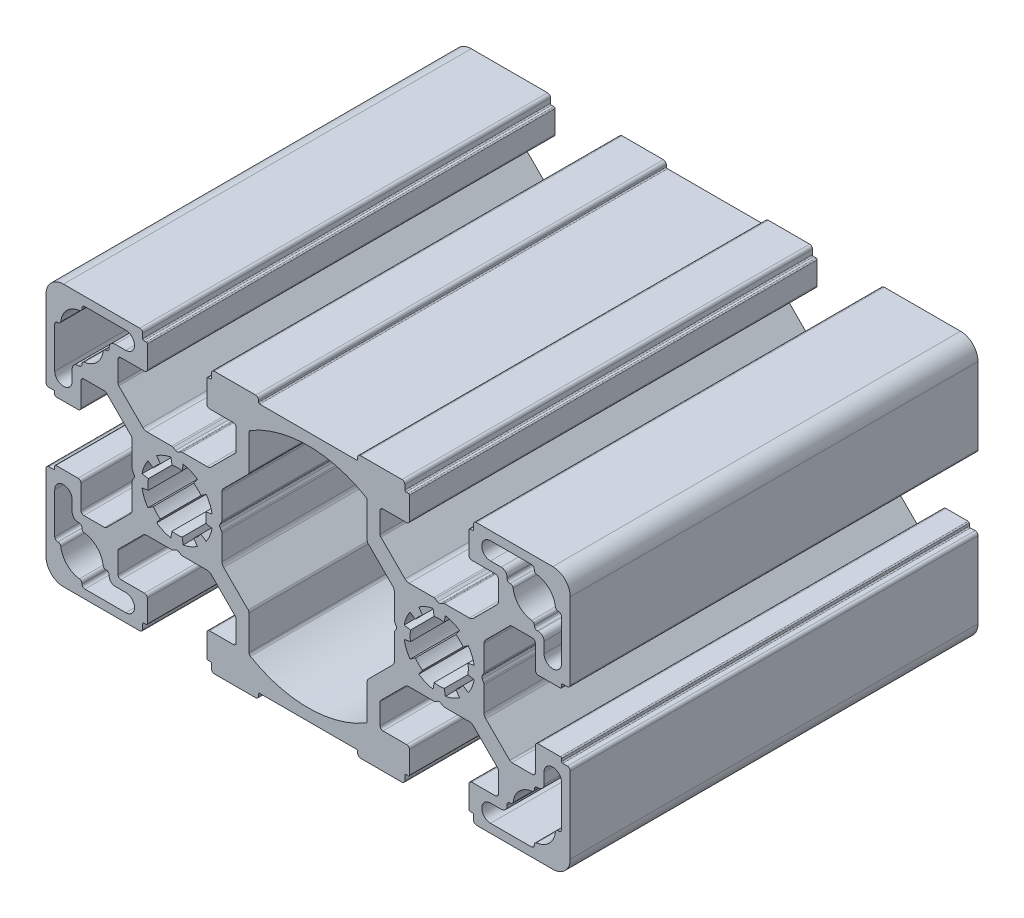
from build123d import *

# Parameters (mm, degrees)
EXTRUDE_2_DEPTH = 70


with BuildPart() as part:
    # Эскиз1 → Бобышка-Вытянуть2 (new body)
    with BuildSketch(Plane.XY):
        with BuildLine():
            Line((-35.141853673, 36.152210307), (-35.141853673, 40.388068593))
            ThreePointArc((-35.141853673, 40.388068593), (-35.21797414, 40.770752026), (-35.434746892, 41.095175374))
            Line((-35.434746892, 41.095175374), (-37.681504654, 43.341933137))
            Line((-37.681504654, 43.341933137), (-39.566246974, 45.226675456))
            ThreePointArc((-39.566246974, 45.226675456), (-39.728458648, 45.335061832), (-39.919800364, 45.373122066))
            Line((-39.919800364, 45.373122066), (-43.441373239, 45.373122066))
            ThreePointArc((-43.441373239, 45.373122066), (-43.79492663, 45.226675456), (-43.941373239, 44.873122066))
            Line((-43.941373239, 44.873122066), (-43.941373239, 40.823122066))
            ThreePointArc((-43.941373239, 40.823122066), (-44.087819849, 40.469568675), (-44.441373239, 40.323122066))
            Line((-44.441373239, 40.323122066), (-48.241373239, 40.323122066))
            ThreePointArc((-48.241373239, 40.323122066), (-48.382794596, 40.381700709), (-48.441373239, 40.523122066))
            Line((-48.441373239, 40.523122066), (-48.441373239, 40.923122066))
            ThreePointArc((-48.441373239, 40.923122066), (-48.499951883, 41.064543422), (-48.641373239, 41.123122066))
            Line((-48.641373239, 41.123122066), (-49.441373239, 41.123122066))
            ThreePointArc((-49.441373239, 41.123122066), (-49.79492663, 41.269568675), (-49.941373239, 41.623122066))
            Line((-49.941373239, 41.623122066), (-49.941373239, 54.723122066))
            ThreePointArc((-49.941373239, 54.723122066), (-49.062693583, 56.844442409), (-46.941373239, 57.723122066))
            Line((-46.941373239, 57.723122066), (-33.841373239, 57.723122066))
            ThreePointArc((-33.841373239, 57.723122066), (-33.487819849, 57.576675456), (-33.341373239, 57.223122066))
            Line((-33.341373239, 57.223122066), (-33.341373239, 56.423122066))
            ThreePointArc((-33.341373239, 56.423122066), (-33.282794596, 56.281700709), (-33.141373239, 56.223122066))
            Line((-33.141373239, 56.223122066), (-32.741373239, 56.223122066))
            ThreePointArc((-32.741373239, 56.223122066), (-32.599951883, 56.164543422), (-32.541373239, 56.023122066))
            Line((-32.541373239, 56.023122066), (-32.541373239, 52.223122066))
            ThreePointArc((-32.541373239, 52.223122066), (-32.687819849, 51.869568675), (-33.041373239, 51.723122066))
            Line((-33.041373239, 51.723122066), (-37.091373239, 51.723122066))
            ThreePointArc((-37.091373239, 51.723122066), (-37.44492663, 51.576675456), (-37.591373239, 51.223122066))
            Line((-37.591373239, 51.223122066), (-37.591373239, 47.70154919))
            ThreePointArc((-37.591373239, 47.70154919), (-37.553313006, 47.510207474), (-37.44492663, 47.3479958))
            Line((-37.44492663, 47.3479958), (-35.560184311, 45.463253481))
            Line((-35.560184311, 45.463253481), (-33.313426548, 43.216495718))
            ThreePointArc((-33.313426548, 43.216495718), (-32.989003199, 42.999722967), (-32.606319767, 42.923602499))
            Line((-32.606319767, 42.923602499), (-28.370461481, 42.923602499))
            ThreePointArc((-28.370461481, 42.923602499), (-28.241051958, 42.906565412), (-28.120461481, 42.856615201))
            Line((-28.120461481, 42.856615201), (-27.691373239, 42.608880989))
            ThreePointArc((-27.691373239, 42.608880989), (-27.441373239, 42.541893691), (-27.191373239, 42.608880989))
            Line((-27.191373239, 42.608880989), (-26.762284998, 42.856615201))
            ThreePointArc((-26.762284998, 42.856615201), (-26.64169452, 42.906565412), (-26.512284998, 42.923602499))
            Line((-26.512284998, 42.923602499), (-22.276426712, 42.923602499))
            ThreePointArc((-22.276426712, 42.923602499), (-21.89374328, 42.999722967), (-21.569319931, 43.216495718))
            Line((-21.569319931, 43.216495718), (-19.322562168, 45.463253481))
            Line((-19.322562168, 45.463253481), (-17.437819849, 47.3479958))
            ThreePointArc((-17.437819849, 47.3479958), (-17.329433473, 47.510207474), (-17.291373239, 47.70154919))
            Line((-17.291373239, 47.70154919), (-17.291373239, 51.223122066))
            ThreePointArc((-17.291373239, 51.223122066), (-17.437819849, 51.576675456), (-17.791373239, 51.723122066))
            Line((-17.791373239, 51.723122066), (-21.841373239, 51.723122066))
            ThreePointArc((-21.841373239, 51.723122066), (-22.19492663, 51.869568675), (-22.341373239, 52.223122066))
            Line((-22.341373239, 52.223122066), (-22.341373239, 56.023122066))
            ThreePointArc((-22.341373239, 56.023122066), (-22.282794596, 56.164543422), (-22.141373239, 56.223122066))
            Line((-22.141373239, 56.223122066), (-21.741373239, 56.223122066))
            ThreePointArc((-21.741373239, 56.223122066), (-21.599951883, 56.281700709), (-21.541373239, 56.423122066))
            Line((-21.541373239, 56.423122066), (-21.541373239, 57.223122066))
            ThreePointArc((-21.541373239, 57.223122066), (-21.39492663, 57.576675456), (-21.041373239, 57.723122066))
            Line((-21.041373239, 57.723122066), (-13.941373239, 57.723122066))
            ThreePointArc((-13.941373239, 57.723122066), (-13.587819849, 57.576675456), (-13.441373239, 57.223122066))
            Line((-13.441373239, 57.223122066), (-13.441373239, 56.923122066))
            ThreePointArc((-13.441373239, 56.923122066), (-13.382794596, 56.781700709), (-13.241373239, 56.723122066))
            Line((-13.241373239, 56.723122066), (3.358626761, 56.723122066))
            ThreePointArc((3.358626761, 56.723122066), (3.500048117, 56.781700709), (3.558626761, 56.923122066))
            Line((3.558626761, 56.923122066), (3.558626761, 57.223122066))
            ThreePointArc((3.558626761, 57.223122066), (3.70507337, 57.576675456), (4.058626761, 57.723122066))
            Line((4.058626761, 57.723122066), (11.158626761, 57.723122066))
            ThreePointArc((11.158626761, 57.723122066), (11.512180151, 57.576675456), (11.658626761, 57.223122066))
            Line((11.658626761, 57.223122066), (11.658626761, 56.423122066))
            ThreePointArc((11.658626761, 56.423122066), (11.717205404, 56.281700709), (11.858626761, 56.223122066))
            Line((11.858626761, 56.223122066), (12.258626761, 56.223122066))
            ThreePointArc((12.258626761, 56.223122066), (12.400048117, 56.164543422), (12.458626761, 56.023122066))
            Line((12.458626761, 56.023122066), (12.458626761, 52.223122066))
            ThreePointArc((12.458626761, 52.223122066), (12.312180151, 51.869568675), (11.958626761, 51.723122066))
            Line((11.958626761, 51.723122066), (7.908626761, 51.723122066))
            ThreePointArc((7.908626761, 51.723122066), (7.55507337, 51.576675456), (7.408626761, 51.223122066))
            Line((7.408626761, 51.223122066), (7.408626761, 47.70154919))
            ThreePointArc((7.408626761, 47.70154919), (7.446686994, 47.510207474), (7.55507337, 47.3479958))
            Line((7.55507337, 47.3479958), (9.439815689, 45.463253481))
            Line((9.439815689, 45.463253481), (11.686573452, 43.216495718))
            ThreePointArc((11.686573452, 43.216495718), (12.010996801, 42.999722967), (12.393680233, 42.923602499))
            Line((12.393680233, 42.923602499), (16.629538519, 42.923602499))
            ThreePointArc((16.629538519, 42.923602499), (16.758948042, 42.906565412), (16.879538519, 42.856615201))
            Line((16.879538519, 42.856615201), (17.308626761, 42.608880989))
            ThreePointArc((17.308626761, 42.608880989), (17.558626761, 42.541893691), (17.808626761, 42.608880989))
            Line((17.808626761, 42.608880989), (18.237715002, 42.856615201))
            ThreePointArc((18.237715002, 42.856615201), (18.35830548, 42.906565412), (18.487715002, 42.923602499))
            Line((18.487715002, 42.923602499), (22.723573288, 42.923602499))
            ThreePointArc((22.723573288, 42.923602499), (23.10625672, 42.999722967), (23.430680069, 43.216495718))
            Line((23.430680069, 43.216495718), (25.677437832, 45.463253481))
            Line((25.677437832, 45.463253481), (27.562180151, 47.3479958))
            ThreePointArc((27.562180151, 47.3479958), (27.670566527, 47.510207474), (27.708626761, 47.70154919))
            Line((27.708626761, 47.70154919), (27.708626761, 51.223122066))
            ThreePointArc((27.708626761, 51.223122066), (27.562180151, 51.576675456), (27.208626761, 51.723122066))
            Line((27.208626761, 51.723122066), (23.158626761, 51.723122066))
            ThreePointArc((23.158626761, 51.723122066), (22.80507337, 51.869568675), (22.658626761, 52.223122066))
            Line((22.658626761, 52.223122066), (22.658626761, 56.023122066))
            ThreePointArc((22.658626761, 56.023122066), (22.717205404, 56.164543422), (22.858626761, 56.223122066))
            Line((22.858626761, 56.223122066), (23.258626761, 56.223122066))
            ThreePointArc((23.258626761, 56.223122066), (23.400048117, 56.281700709), (23.458626761, 56.423122066))
            Line((23.458626761, 56.423122066), (23.458626761, 57.223122066))
            ThreePointArc((23.458626761, 57.223122066), (23.60507337, 57.576675456), (23.958626761, 57.723122066))
            Line((23.958626761, 57.723122066), (37.058626761, 57.723122066))
            ThreePointArc((37.058626761, 57.723122066), (39.179947104, 56.844442409), (40.058626761, 54.723122066))
            Line((40.058626761, 54.723122066), (40.058626761, 41.623122066))
            ThreePointArc((40.058626761, 41.623122066), (39.912180151, 41.269568675), (39.558626761, 41.123122066))
            Line((39.558626761, 41.123122066), (38.758626761, 41.123122066))
            ThreePointArc((38.758626761, 41.123122066), (38.617205404, 41.064543422), (38.558626761, 40.923122066))
            Line((38.558626761, 40.923122066), (38.558626761, 40.523122066))
            ThreePointArc((38.558626761, 40.523122066), (38.500048117, 40.381700709), (38.358626761, 40.323122066))
            Line((38.358626761, 40.323122066), (34.558626761, 40.323122066))
            ThreePointArc((34.558626761, 40.323122066), (34.20507337, 40.469568675), (34.058626761, 40.823122066))
            Line((34.058626761, 40.823122066), (34.058626761, 44.873122066))
            ThreePointArc((34.058626761, 44.873122066), (33.912180151, 45.226675456), (33.558626761, 45.373122066))
            Line((33.558626761, 45.373122066), (30.037053885, 45.373122066))
            ThreePointArc((30.037053885, 45.373122066), (29.845712169, 45.335061832), (29.683500495, 45.226675456))
            Line((29.683500495, 45.226675456), (27.798758175, 43.341933137))
            Line((27.798758175, 43.341933137), (25.552000413, 41.095175374))
            ThreePointArc((25.552000413, 41.095175374), (25.335227661, 40.770752026), (25.259107194, 40.388068593))
            Line((25.259107194, 40.388068593), (25.259107194, 36.152210307))
            ThreePointArc((25.259107194, 36.152210307), (25.242070107, 36.022800785), (25.192119896, 35.902210307))
            Line((25.192119896, 35.902210307), (24.944385684, 35.473122066))
            ThreePointArc((24.944385684, 35.473122066), (24.877398386, 35.223122066), (24.944385684, 34.973122066))
            Line((24.944385684, 34.973122066), (25.192119896, 34.544033824))
            ThreePointArc((25.192119896, 34.544033824), (25.242070107, 34.423443347), (25.259107194, 34.294033824))
            Line((25.259107194, 34.294033824), (25.259107194, 30.058175538))
            ThreePointArc((25.259107194, 30.058175538), (25.335227661, 29.675492106), (25.552000413, 29.351068757))
            Line((25.552000413, 29.351068757), (27.798758175, 27.104310994))
            Line((27.798758175, 27.104310994), (29.683500495, 25.219568675))
            ThreePointArc((29.683500495, 25.219568675), (29.845712169, 25.111182299), (30.037053885, 25.073122066))
            Line((30.037053885, 25.073122066), (33.558626761, 25.073122066))
            ThreePointArc((33.558626761, 25.073122066), (33.912180151, 25.219568675), (34.058626761, 25.573122066))
            Line((34.058626761, 25.573122066), (34.058626761, 29.623122066))
            ThreePointArc((34.058626761, 29.623122066), (34.20507337, 29.976675456), (34.558626761, 30.123122066))
            Line((34.558626761, 30.123122066), (38.358626761, 30.123122066))
            ThreePointArc((38.358626761, 30.123122066), (38.500048117, 30.064543422), (38.558626761, 29.923122066))
            Line((38.558626761, 29.923122066), (38.558626761, 29.523122066))
            ThreePointArc((38.558626761, 29.523122066), (38.617205404, 29.381700709), (38.758626761, 29.323122066))
            Line((38.758626761, 29.323122066), (39.558626761, 29.323122066))
            ThreePointArc((39.558626761, 29.323122066), (39.912180151, 29.176675456), (40.058626761, 28.823122066))
            Line((40.058626761, 28.823122066), (40.058626761, 15.723122066))
            ThreePointArc((40.058626761, 15.723122066), (39.179947104, 13.601801722), (37.058626761, 12.723122066))
            Line((37.058626761, 12.723122066), (23.958626761, 12.723122066))
            ThreePointArc((23.958626761, 12.723122066), (23.60507337, 12.869568675), (23.458626761, 13.223122066))
            Line((23.458626761, 13.223122066), (23.458626761, 14.023122066))
            ThreePointArc((23.458626761, 14.023122066), (23.400048117, 14.164543422), (23.258626761, 14.223122066))
            Line((23.258626761, 14.223122066), (22.858626761, 14.223122066))
            ThreePointArc((22.858626761, 14.223122066), (22.717205404, 14.281700709), (22.658626761, 14.423122066))
            Line((22.658626761, 14.423122066), (22.658626761, 18.223122066))
            ThreePointArc((22.658626761, 18.223122066), (22.80507337, 18.576675456), (23.158626761, 18.723122066))
            Line((23.158626761, 18.723122066), (27.208626761, 18.723122066))
            ThreePointArc((27.208626761, 18.723122066), (27.562180151, 18.869568675), (27.708626761, 19.223122066))
            Line((27.708626761, 19.223122066), (27.708626761, 22.744694941))
            ThreePointArc((27.708626761, 22.744694941), (27.670566527, 22.936036657), (27.562180151, 23.098248332))
            Line((27.562180151, 23.098248332), (25.677437832, 24.982990651))
            Line((25.677437832, 24.982990651), (23.430680069, 27.229748413))
            ThreePointArc((23.430680069, 27.229748413), (23.10625672, 27.446521165), (22.723573288, 27.522641632))
            Line((22.723573288, 27.522641632), (18.487715002, 27.522641632))
            ThreePointArc((18.487715002, 27.522641632), (18.35830548, 27.539678719), (18.237715002, 27.58962893))
            Line((18.237715002, 27.58962893), (17.808626761, 27.837363142))
            ThreePointArc((17.808626761, 27.837363142), (17.558626761, 27.90435044), (17.308626761, 27.837363142))
            Line((17.308626761, 27.837363142), (16.879538519, 27.58962893))
            ThreePointArc((16.879538519, 27.58962893), (16.758948042, 27.539678719), (16.629538519, 27.522641632))
            Line((16.629538519, 27.522641632), (12.393680233, 27.522641632))
            ThreePointArc((12.393680233, 27.522641632), (12.010996801, 27.446521165), (11.686573452, 27.229748413))
            Line((11.686573452, 27.229748413), (9.439815689, 24.982990651))
            Line((9.439815689, 24.982990651), (7.55507337, 23.098248332))
            ThreePointArc((7.55507337, 23.098248332), (7.446686994, 22.936036657), (7.408626761, 22.744694941))
            Line((7.408626761, 22.744694941), (7.408626761, 19.223122066))
            ThreePointArc((7.408626761, 19.223122066), (7.55507337, 18.869568675), (7.908626761, 18.723122066))
            Line((7.908626761, 18.723122066), (11.958626761, 18.723122066))
            ThreePointArc((11.958626761, 18.723122066), (12.312180151, 18.576675456), (12.458626761, 18.223122066))
            Line((12.458626761, 18.223122066), (12.458626761, 14.423122066))
            ThreePointArc((12.458626761, 14.423122066), (12.400048117, 14.281700709), (12.258626761, 14.223122066))
            Line((12.258626761, 14.223122066), (11.858626761, 14.223122066))
            ThreePointArc((11.858626761, 14.223122066), (11.717205404, 14.164543422), (11.658626761, 14.023122066))
            Line((11.658626761, 14.023122066), (11.658626761, 13.223122066))
            ThreePointArc((11.658626761, 13.223122066), (11.512180151, 12.869568675), (11.158626761, 12.723122066))
            Line((11.158626761, 12.723122066), (4.058626761, 12.723122066))
            ThreePointArc((4.058626761, 12.723122066), (3.70507337, 12.869568675), (3.558626761, 13.223122066))
            Line((3.558626761, 13.223122066), (3.558626761, 13.523122066))
            ThreePointArc((3.558626761, 13.523122066), (3.500048117, 13.664543422), (3.358626761, 13.723122066))
            Line((3.358626761, 13.723122066), (-13.241373239, 13.723122066))
            ThreePointArc((-13.241373239, 13.723122066), (-13.382794596, 13.664543422), (-13.441373239, 13.523122066))
            Line((-13.441373239, 13.523122066), (-13.441373239, 13.223122066))
            ThreePointArc((-13.441373239, 13.223122066), (-13.587819849, 12.869568675), (-13.941373239, 12.723122066))
            Line((-13.941373239, 12.723122066), (-21.041373239, 12.723122066))
            ThreePointArc((-21.041373239, 12.723122066), (-21.39492663, 12.869568675), (-21.541373239, 13.223122066))
            Line((-21.541373239, 13.223122066), (-21.541373239, 14.023122066))
            ThreePointArc((-21.541373239, 14.023122066), (-21.599951883, 14.164543422), (-21.741373239, 14.223122066))
            Line((-21.741373239, 14.223122066), (-22.141373239, 14.223122066))
            ThreePointArc((-22.141373239, 14.223122066), (-22.282794596, 14.281700709), (-22.341373239, 14.423122066))
            Line((-22.341373239, 14.423122066), (-22.341373239, 18.223122066))
            ThreePointArc((-22.341373239, 18.223122066), (-22.19492663, 18.576675456), (-21.841373239, 18.723122066))
            Line((-21.841373239, 18.723122066), (-17.791373239, 18.723122066))
            ThreePointArc((-17.791373239, 18.723122066), (-17.437819849, 18.869568675), (-17.291373239, 19.223122066))
            Line((-17.291373239, 19.223122066), (-17.291373239, 22.744694941))
            ThreePointArc((-17.291373239, 22.744694941), (-17.329433473, 22.936036657), (-17.437819849, 23.098248332))
            Line((-17.437819849, 23.098248332), (-19.322562168, 24.982990651))
            Line((-19.322562168, 24.982990651), (-21.569319931, 27.229748413))
            ThreePointArc((-21.569319931, 27.229748413), (-21.89374328, 27.446521165), (-22.276426712, 27.522641632))
            Line((-22.276426712, 27.522641632), (-26.512284998, 27.522641632))
            ThreePointArc((-26.512284998, 27.522641632), (-26.64169452, 27.539678719), (-26.762284998, 27.58962893))
            Line((-26.762284998, 27.58962893), (-27.191373239, 27.837363142))
            ThreePointArc((-27.191373239, 27.837363142), (-27.441373239, 27.90435044), (-27.691373239, 27.837363142))
            Line((-27.691373239, 27.837363142), (-28.120461481, 27.58962893))
            ThreePointArc((-28.120461481, 27.58962893), (-28.241051958, 27.539678719), (-28.370461481, 27.522641632))
            Line((-28.370461481, 27.522641632), (-32.606319767, 27.522641632))
            ThreePointArc((-32.606319767, 27.522641632), (-32.989003199, 27.446521165), (-33.313426548, 27.229748413))
            Line((-33.313426548, 27.229748413), (-35.560184311, 24.982990651))
            Line((-35.560184311, 24.982990651), (-37.44492663, 23.098248332))
            ThreePointArc((-37.44492663, 23.098248332), (-37.553313006, 22.936036657), (-37.591373239, 22.744694941))
            Line((-37.591373239, 22.744694941), (-37.591373239, 19.223122066))
            ThreePointArc((-37.591373239, 19.223122066), (-37.44492663, 18.869568675), (-37.091373239, 18.723122066))
            Line((-37.091373239, 18.723122066), (-33.041373239, 18.723122066))
            ThreePointArc((-33.041373239, 18.723122066), (-32.687819849, 18.576675456), (-32.541373239, 18.223122066))
            Line((-32.541373239, 18.223122066), (-32.541373239, 14.423122066))
            ThreePointArc((-32.541373239, 14.423122066), (-32.599951883, 14.281700709), (-32.741373239, 14.223122066))
            Line((-32.741373239, 14.223122066), (-33.141373239, 14.223122066))
            ThreePointArc((-33.141373239, 14.223122066), (-33.282794596, 14.164543422), (-33.341373239, 14.023122066))
            Line((-33.341373239, 14.023122066), (-33.341373239, 13.223122066))
            ThreePointArc((-33.341373239, 13.223122066), (-33.487819849, 12.869568675), (-33.841373239, 12.723122066))
            Line((-33.841373239, 12.723122066), (-46.941373239, 12.723122066))
            ThreePointArc((-46.941373239, 12.723122066), (-49.062693583, 13.601801722), (-49.941373239, 15.723122066))
            Line((-49.941373239, 15.723122066), (-49.941373239, 28.823122066))
            ThreePointArc((-49.941373239, 28.823122066), (-49.79492663, 29.176675456), (-49.441373239, 29.323122066))
            Line((-49.441373239, 29.323122066), (-48.641373239, 29.323122066))
            ThreePointArc((-48.641373239, 29.323122066), (-48.499951883, 29.381700709), (-48.441373239, 29.523122066))
            Line((-48.441373239, 29.523122066), (-48.441373239, 29.923122066))
            ThreePointArc((-48.441373239, 29.923122066), (-48.382794596, 30.064543422), (-48.241373239, 30.123122066))
            Line((-48.241373239, 30.123122066), (-44.441373239, 30.123122066))
            ThreePointArc((-44.441373239, 30.123122066), (-44.087819849, 29.976675456), (-43.941373239, 29.623122066))
            Line((-43.941373239, 29.623122066), (-43.941373239, 25.573122066))
            ThreePointArc((-43.941373239, 25.573122066), (-43.79492663, 25.219568675), (-43.441373239, 25.073122066))
            Line((-43.441373239, 25.073122066), (-39.919800364, 25.073122066))
            ThreePointArc((-39.919800364, 25.073122066), (-39.728458648, 25.111182299), (-39.566246974, 25.219568675))
            Line((-39.566246974, 25.219568675), (-37.681504654, 27.104310994))
            Line((-37.681504654, 27.104310994), (-35.434746892, 29.351068757))
            ThreePointArc((-35.434746892, 29.351068757), (-35.21797414, 29.675492106), (-35.141853673, 30.058175538))
            Line((-35.141853673, 30.058175538), (-35.141853673, 34.294033824))
            ThreePointArc((-35.141853673, 34.294033824), (-35.124816586, 34.423443347), (-35.074866375, 34.544033824))
            Line((-35.074866375, 34.544033824), (-34.827132163, 34.973122066))
            ThreePointArc((-34.827132163, 34.973122066), (-34.760144865, 35.223122066), (-34.827132163, 35.473122066))
            Line((-34.827132163, 35.473122066), (-35.074866375, 35.902210307))
            ThreePointArc((-35.074866375, 35.902210307), (-35.124816586, 36.022800785), (-35.141853673, 36.152210307))
        make_face()
        with BuildLine():
            Line((-48.441373239, 51.048122066), (-48.441373239, 44.031073139))
            ThreePointArc((-48.441373239, 44.031073139), (-46.941373239, 42.531073139), (-45.441373239, 44.031073139))
            Line((-45.441373239, 44.031073139), (-45.441373239, 45.873122066))
            ThreePointArc((-45.441373239, 45.873122066), (-45.148480021, 46.580228847), (-44.441373239, 46.873122066))
            Line((-44.441373239, 46.873122066), (-44.266373239, 46.873122066))
            ThreePointArc((-44.266373239, 46.873122066), (-43.912819849, 47.019568675), (-43.766373239, 47.373122066))
            Line((-43.766373239, 47.373122066), (-43.766373239, 47.428352655))
            ThreePointArc((-43.766373239, 47.428352655), (-43.64061947, 47.759924305), (-43.326614203, 47.924710415))
            ThreePointArc((-43.326614203, 47.924710415), (-41.185433488, 48.967182314), (-40.142961589, 51.10836303))
            ThreePointArc((-40.142961589, 51.10836303), (-39.978175478, 51.422368296), (-39.646603828, 51.548122066))
            Line((-39.646603828, 51.548122066), (-39.591373239, 51.548122066))
            ThreePointArc((-39.591373239, 51.548122066), (-39.237819849, 51.694568675), (-39.091373239, 52.048122066))
            Line((-39.091373239, 52.048122066), (-39.091373239, 52.223122066))
            ThreePointArc((-39.091373239, 52.223122066), (-38.798480021, 52.930228847), (-38.091373239, 53.223122066))
            Line((-38.091373239, 53.223122066), (-36.249324313, 53.223122066))
            ThreePointArc((-36.249324313, 53.223122066), (-34.749324313, 54.723122066), (-36.249324313, 56.223122066))
            Line((-36.249324313, 56.223122066), (-43.266373239, 56.223122066))
            ThreePointArc((-43.266373239, 56.223122066), (-43.61992663, 56.076675456), (-43.766373239, 55.723122066))
            Line((-43.766373239, 55.723122066), (-43.766373239, 55.667891477))
            ThreePointArc((-43.766373239, 55.667891477), (-43.892127009, 55.336319827), (-44.206132276, 55.171533716))
            ThreePointArc((-44.206132276, 55.171533716), (-46.347312991, 54.129061817), (-47.38978489, 51.987881102))
            ThreePointArc((-47.38978489, 51.987881102), (-47.554571001, 51.673875835), (-47.88614265, 51.548122066))
            Line((-47.88614265, 51.548122066), (-47.941373239, 51.548122066))
            ThreePointArc((-47.941373239, 51.548122066), (-48.29492663, 51.401675456), (-48.441373239, 51.048122066))
        make_face(mode=Mode.SUBTRACT)
        with BuildLine():
            Line((-43.266373239, 14.223122066), (-36.249324313, 14.223122066))
            ThreePointArc((-36.249324313, 14.223122066), (-34.749324313, 15.723122066), (-36.249324313, 17.223122066))
            Line((-36.249324313, 17.223122066), (-38.091373239, 17.223122066))
            ThreePointArc((-38.091373239, 17.223122066), (-38.798480021, 17.516015285), (-39.091373239, 18.223122066))
            Line((-39.091373239, 18.223122066), (-39.091373239, 18.398122066))
            ThreePointArc((-39.091373239, 18.398122066), (-39.237819849, 18.751675456), (-39.591373239, 18.898122066))
            Line((-39.591373239, 18.898122066), (-39.646603828, 18.898122066))
            ThreePointArc((-39.646603828, 18.898122066), (-39.978175478, 19.023875835), (-40.142961589, 19.337881102))
            ThreePointArc((-40.142961589, 19.337881102), (-41.185433488, 21.479061817), (-43.326614203, 22.521533716))
            ThreePointArc((-43.326614203, 22.521533716), (-43.64061947, 22.686319827), (-43.766373239, 23.017891477))
            Line((-43.766373239, 23.017891477), (-43.766373239, 23.073122066))
            ThreePointArc((-43.766373239, 23.073122066), (-43.912819849, 23.426675456), (-44.266373239, 23.573122066))
            Line((-44.266373239, 23.573122066), (-44.441373239, 23.573122066))
            ThreePointArc((-44.441373239, 23.573122066), (-45.148480021, 23.866015285), (-45.441373239, 24.573122066))
            Line((-45.441373239, 24.573122066), (-45.441373239, 26.415170992))
            ThreePointArc((-45.441373239, 26.415170992), (-46.941373239, 27.915170992), (-48.441373239, 26.415170992))
            Line((-48.441373239, 26.415170992), (-48.441373239, 19.398122066))
            ThreePointArc((-48.441373239, 19.398122066), (-48.29492663, 19.044568675), (-47.941373239, 18.898122066))
            Line((-47.941373239, 18.898122066), (-47.88614265, 18.898122066))
            ThreePointArc((-47.88614265, 18.898122066), (-47.554571001, 18.772368296), (-47.38978489, 18.45836303))
            ThreePointArc((-47.38978489, 18.45836303), (-46.347312991, 16.317182314), (-44.206132276, 15.274710415))
            ThreePointArc((-44.206132276, 15.274710415), (-43.892127009, 15.109924305), (-43.766373239, 14.778352655))
            Line((-43.766373239, 14.778352655), (-43.766373239, 14.723122066))
            ThreePointArc((-43.766373239, 14.723122066), (-43.61992663, 14.369568675), (-43.266373239, 14.223122066))
        make_face(mode=Mode.SUBTRACT)
        with BuildLine():
            Line((-15.091373239, 49.462335628), (-15.091373239, 45.658908503))
            ThreePointArc((-15.091373239, 45.658908503), (-15.129433473, 45.467566787), (-15.237819849, 45.305355113))
            Line((-15.237819849, 45.305355113), (-17.201241825, 43.341933137))
            Line((-17.201241825, 43.341933137), (-19.447999587, 41.095175374))
            ThreePointArc((-19.447999587, 41.095175374), (-19.664772339, 40.770752026), (-19.740892806, 40.388068593))
            Line((-19.740892806, 40.388068593), (-19.740892806, 36.152210307))
            ThreePointArc((-19.740892806, 36.152210307), (-19.757929893, 36.022800785), (-19.807880104, 35.902210307))
            Line((-19.807880104, 35.902210307), (-20.055614316, 35.473122066))
            ThreePointArc((-20.055614316, 35.473122066), (-20.122601614, 35.223122066), (-20.055614316, 34.973122066))
            Line((-20.055614316, 34.973122066), (-19.807880104, 34.544033824))
            ThreePointArc((-19.807880104, 34.544033824), (-19.757929893, 34.423443347), (-19.740892806, 34.294033824))
            Line((-19.740892806, 34.294033824), (-19.740892806, 30.058175538))
            ThreePointArc((-19.740892806, 30.058175538), (-19.664772339, 29.675492106), (-19.447999587, 29.351068757))
            Line((-19.447999587, 29.351068757), (-17.201241825, 27.104310994))
            Line((-17.201241825, 27.104310994), (-15.237819849, 25.140889019))
            ThreePointArc((-15.237819849, 25.140889019), (-15.129433473, 24.978677344), (-15.091373239, 24.787335628))
            Line((-15.091373239, 24.787335628), (-15.091373239, 20.983908503))
            Line((-15.091373239, 20.983908503), (-15.091373239, 18.856158389))
            ThreePointArc((-15.091373239, 18.856158389), (-15.025523953, 18.608139926), (-14.845320608, 18.425448818))
            ThreePointArc((-14.845320608, 18.425448818), (-4.941373239, 15.723122066), (4.962574129, 18.425448818))
            ThreePointArc((4.962574129, 18.425448818), (5.142777474, 18.608139926), (5.208626761, 18.856158389))
            Line((5.208626761, 18.856158389), (5.208626761, 20.983908503))
            Line((5.208626761, 20.983908503), (5.208626761, 24.787335628))
            ThreePointArc((5.208626761, 24.787335628), (5.246686994, 24.978677344), (5.35507337, 25.140889019))
            Line((5.35507337, 25.140889019), (7.318495346, 27.104310994))
            Line((7.318495346, 27.104310994), (9.565253108, 29.351068757))
            ThreePointArc((9.565253108, 29.351068757), (9.78202586, 29.675492106), (9.858146327, 30.058175538))
            Line((9.858146327, 30.058175538), (9.858146327, 34.294033824))
            ThreePointArc((9.858146327, 34.294033824), (9.875183414, 34.423443347), (9.925133625, 34.544033824))
            Line((9.925133625, 34.544033824), (10.172867837, 34.973122066))
            ThreePointArc((10.172867837, 34.973122066), (10.239855135, 35.223122066), (10.172867837, 35.473122066))
            Line((10.172867837, 35.473122066), (9.925133625, 35.902210307))
            ThreePointArc((9.925133625, 35.902210307), (9.875183414, 36.022800785), (9.858146327, 36.152210307))
            Line((9.858146327, 36.152210307), (9.858146327, 40.388068593))
            ThreePointArc((9.858146327, 40.388068593), (9.78202586, 40.770752026), (9.565253108, 41.095175374))
            Line((9.565253108, 41.095175374), (7.318495346, 43.341933137))
            Line((7.318495346, 43.341933137), (5.35507337, 45.305355113))
            ThreePointArc((5.35507337, 45.305355113), (5.246686994, 45.467566787), (5.208626761, 45.658908503))
            Line((5.208626761, 45.658908503), (5.208626761, 49.462335628))
            Line((5.208626761, 49.462335628), (5.208626761, 51.590085743))
            ThreePointArc((5.208626761, 51.590085743), (5.142777474, 51.838104205), (4.962574129, 52.020795313))
            ThreePointArc((4.962574129, 52.020795313), (-4.941373239, 54.723122066), (-14.845320608, 52.020795313))
            ThreePointArc((-14.845320608, 52.020795313), (-15.025523953, 51.838104205), (-15.091373239, 51.590085743))
            Line((-15.091373239, 51.590085743), (-15.091373239, 49.462335628))
        make_face(mode=Mode.SUBTRACT)
        with BuildLine():
            Line((-30.309255421, 39.318882287), (-30.940189501, 40.219949536))
            ThreePointArc((-30.940189501, 40.219949536), (-29.775742177, 40.858787214), (-28.500627123, 41.230449359))
            Line((-28.500627123, 41.230449359), (-28.309614128, 40.147160831))
            ThreePointArc((-28.309614128, 40.147160831), (-27.441373239, 40.223122066), (-26.573132351, 40.147160831))
            Line((-26.573132351, 40.147160831), (-26.382119356, 41.230449359))
            ThreePointArc((-26.382119356, 41.230449359), (-25.107004302, 40.858787214), (-23.942556978, 40.219949536))
            Line((-23.942556978, 40.219949536), (-24.573491058, 39.318882287))
            ThreePointArc((-24.573491058, 39.318882287), (-23.905839334, 38.758655972), (-23.345613018, 38.091004247))
            Line((-23.345613018, 38.091004247), (-22.444545769, 38.721938327))
            ThreePointArc((-22.444545769, 38.721938327), (-21.805708091, 37.557491003), (-21.434045946, 36.282375949))
            Line((-21.434045946, 36.282375949), (-22.517334474, 36.091362954))
            ThreePointArc((-22.517334474, 36.091362954), (-22.441373239, 35.223122066), (-22.517334474, 34.354881177))
            Line((-22.517334474, 34.354881177), (-21.434045946, 34.163868182))
            ThreePointArc((-21.434045946, 34.163868182), (-21.805708091, 32.888753128), (-22.444545769, 31.724305804))
            Line((-22.444545769, 31.724305804), (-23.345613018, 32.355239884))
            ThreePointArc((-23.345613018, 32.355239884), (-23.905839334, 31.68758816), (-24.573491058, 31.127361844))
            Line((-24.573491058, 31.127361844), (-23.942556978, 30.226294596))
            ThreePointArc((-23.942556978, 30.226294596), (-25.107004302, 29.587456917), (-26.382119356, 29.215794772))
            Line((-26.382119356, 29.215794772), (-26.573132351, 30.299083301))
            ThreePointArc((-26.573132351, 30.299083301), (-27.441373239, 30.223122066), (-28.309614128, 30.299083301))
            Line((-28.309614128, 30.299083301), (-28.500627123, 29.215794772))
            ThreePointArc((-28.500627123, 29.215794772), (-29.775742177, 29.587456917), (-30.940189501, 30.226294596))
            Line((-30.940189501, 30.226294596), (-30.309255421, 31.127361844))
            ThreePointArc((-30.309255421, 31.127361844), (-30.976907145, 31.68758816), (-31.537133461, 32.355239884))
            Line((-31.537133461, 32.355239884), (-32.43820071, 31.724305804))
            ThreePointArc((-32.43820071, 31.724305804), (-33.077038388, 32.888753128), (-33.448700533, 34.163868182))
            Line((-33.448700533, 34.163868182), (-32.365412004, 34.354881177))
            ThreePointArc((-32.365412004, 34.354881177), (-32.441373239, 35.223122066), (-32.365412004, 36.091362954))
            Line((-32.365412004, 36.091362954), (-33.448700533, 36.282375949))
            ThreePointArc((-33.448700533, 36.282375949), (-33.077038388, 37.557491003), (-32.43820071, 38.721938327))
            Line((-32.43820071, 38.721938327), (-31.537133461, 38.091004247))
            ThreePointArc((-31.537133461, 38.091004247), (-30.976907145, 38.758655972), (-30.309255421, 39.318882287))
        make_face(mode=Mode.SUBTRACT)
        with BuildLine():
            Line((38.558626761, 19.398122066), (38.558626761, 26.415170992))
            ThreePointArc((38.558626761, 26.415170992), (37.058626761, 27.915170992), (35.558626761, 26.415170992))
            Line((35.558626761, 26.415170992), (35.558626761, 24.573122066))
            ThreePointArc((35.558626761, 24.573122066), (35.265733542, 23.866015285), (34.558626761, 23.573122066))
            Line((34.558626761, 23.573122066), (34.383626761, 23.573122066))
            ThreePointArc((34.383626761, 23.573122066), (34.03007337, 23.426675456), (33.883626761, 23.073122066))
            Line((33.883626761, 23.073122066), (33.883626761, 23.017891477))
            ThreePointArc((33.883626761, 23.017891477), (33.757872991, 22.686319827), (33.443867724, 22.521533716))
            ThreePointArc((33.443867724, 22.521533716), (31.302687009, 21.479061817), (30.26021511, 19.337881102))
            ThreePointArc((30.26021511, 19.337881102), (30.095428999, 19.023875835), (29.76385735, 18.898122066))
            Line((29.76385735, 18.898122066), (29.708626761, 18.898122066))
            ThreePointArc((29.708626761, 18.898122066), (29.35507337, 18.751675456), (29.208626761, 18.398122066))
            Line((29.208626761, 18.398122066), (29.208626761, 18.223122066))
            ThreePointArc((29.208626761, 18.223122066), (28.915733542, 17.516015285), (28.208626761, 17.223122066))
            Line((28.208626761, 17.223122066), (26.366577834, 17.223122066))
            ThreePointArc((26.366577834, 17.223122066), (24.866577834, 15.723122066), (26.366577834, 14.223122066))
            Line((26.366577834, 14.223122066), (33.383626761, 14.223122066))
            ThreePointArc((33.383626761, 14.223122066), (33.737180151, 14.369568675), (33.883626761, 14.723122066))
            Line((33.883626761, 14.723122066), (33.883626761, 14.778352655))
            ThreePointArc((33.883626761, 14.778352655), (34.00938053, 15.109924305), (34.323385797, 15.274710415))
            ThreePointArc((34.323385797, 15.274710415), (36.464566512, 16.317182314), (37.507038411, 18.45836303))
            ThreePointArc((37.507038411, 18.45836303), (37.671824522, 18.772368296), (38.003396172, 18.898122066))
            Line((38.003396172, 18.898122066), (38.058626761, 18.898122066))
            ThreePointArc((38.058626761, 18.898122066), (38.412180151, 19.044568675), (38.558626761, 19.398122066))
        make_face(mode=Mode.SUBTRACT)
        with BuildLine():
            Line((20.426508942, 31.127361844), (21.057443022, 30.226294596))
            ThreePointArc((21.057443022, 30.226294596), (19.892995698, 29.587456917), (18.617880644, 29.215794772))
            Line((18.617880644, 29.215794772), (18.426867649, 30.299083301))
            ThreePointArc((18.426867649, 30.299083301), (17.558626761, 30.223122066), (16.690385872, 30.299083301))
            Line((16.690385872, 30.299083301), (16.499372877, 29.215794772))
            ThreePointArc((16.499372877, 29.215794772), (15.224257823, 29.587456917), (14.059810499, 30.226294596))
            Line((14.059810499, 30.226294596), (14.690744579, 31.127361844))
            ThreePointArc((14.690744579, 31.127361844), (14.023092855, 31.68758816), (13.462866539, 32.355239884))
            Line((13.462866539, 32.355239884), (12.56179929, 31.724305804))
            ThreePointArc((12.56179929, 31.724305804), (11.922961612, 32.888753128), (11.551299467, 34.163868182))
            Line((11.551299467, 34.163868182), (12.634587996, 34.354881177))
            ThreePointArc((12.634587996, 34.354881177), (12.558626761, 35.223122066), (12.634587996, 36.091362954))
            Line((12.634587996, 36.091362954), (11.551299467, 36.282375949))
            ThreePointArc((11.551299467, 36.282375949), (11.922961612, 37.557491003), (12.56179929, 38.721938327))
            Line((12.56179929, 38.721938327), (13.462866539, 38.091004247))
            ThreePointArc((13.462866539, 38.091004247), (14.023092855, 38.758655972), (14.690744579, 39.318882287))
            Line((14.690744579, 39.318882287), (14.059810499, 40.219949536))
            ThreePointArc((14.059810499, 40.219949536), (15.224257823, 40.858787214), (16.499372877, 41.230449359))
            Line((16.499372877, 41.230449359), (16.690385872, 40.147160831))
            ThreePointArc((16.690385872, 40.147160831), (17.558626761, 40.223122066), (18.426867649, 40.147160831))
            Line((18.426867649, 40.147160831), (18.617880644, 41.230449359))
            ThreePointArc((18.617880644, 41.230449359), (19.892995698, 40.858787214), (21.057443022, 40.219949536))
            Line((21.057443022, 40.219949536), (20.426508942, 39.318882287))
            ThreePointArc((20.426508942, 39.318882287), (21.094160666, 38.758655972), (21.654386982, 38.091004247))
            Line((21.654386982, 38.091004247), (22.555454231, 38.721938327))
            ThreePointArc((22.555454231, 38.721938327), (23.194291909, 37.557491003), (23.565954054, 36.282375949))
            Line((23.565954054, 36.282375949), (22.482665526, 36.091362954))
            ThreePointArc((22.482665526, 36.091362954), (22.558626761, 35.223122066), (22.482665526, 34.354881177))
            Line((22.482665526, 34.354881177), (23.565954054, 34.163868182))
            ThreePointArc((23.565954054, 34.163868182), (23.194291909, 32.888753128), (22.555454231, 31.724305804))
            Line((22.555454231, 31.724305804), (21.654386982, 32.355239884))
            ThreePointArc((21.654386982, 32.355239884), (21.094160666, 31.68758816), (20.426508942, 31.127361844))
        make_face(mode=Mode.SUBTRACT)
        with BuildLine():
            Line((33.383626761, 56.223122066), (26.366577834, 56.223122066))
            ThreePointArc((26.366577834, 56.223122066), (24.866577834, 54.723122066), (26.366577834, 53.223122066))
            Line((26.366577834, 53.223122066), (28.208626761, 53.223122066))
            ThreePointArc((28.208626761, 53.223122066), (28.915733542, 52.930228847), (29.208626761, 52.223122066))
            Line((29.208626761, 52.223122066), (29.208626761, 52.048122066))
            ThreePointArc((29.208626761, 52.048122066), (29.35507337, 51.694568675), (29.708626761, 51.548122066))
            Line((29.708626761, 51.548122066), (29.76385735, 51.548122066))
            ThreePointArc((29.76385735, 51.548122066), (30.095428999, 51.422368296), (30.26021511, 51.10836303))
            ThreePointArc((30.26021511, 51.10836303), (31.302687009, 48.967182314), (33.443867724, 47.924710415))
            ThreePointArc((33.443867724, 47.924710415), (33.757872991, 47.759924305), (33.883626761, 47.428352655))
            Line((33.883626761, 47.428352655), (33.883626761, 47.373122066))
            ThreePointArc((33.883626761, 47.373122066), (34.03007337, 47.019568675), (34.383626761, 46.873122066))
            Line((34.383626761, 46.873122066), (34.558626761, 46.873122066))
            ThreePointArc((34.558626761, 46.873122066), (35.265733542, 46.580228847), (35.558626761, 45.873122066))
            Line((35.558626761, 45.873122066), (35.558626761, 44.031073139))
            ThreePointArc((35.558626761, 44.031073139), (37.058626761, 42.531073139), (38.558626761, 44.031073139))
            Line((38.558626761, 44.031073139), (38.558626761, 51.048122066))
            ThreePointArc((38.558626761, 51.048122066), (38.412180151, 51.401675456), (38.058626761, 51.548122066))
            Line((38.058626761, 51.548122066), (38.003396172, 51.548122066))
            ThreePointArc((38.003396172, 51.548122066), (37.671824522, 51.673875835), (37.507038411, 51.987881102))
            ThreePointArc((37.507038411, 51.987881102), (36.464566512, 54.129061817), (34.323385797, 55.171533716))
            ThreePointArc((34.323385797, 55.171533716), (34.00938053, 55.336319827), (33.883626761, 55.667891477))
            Line((33.883626761, 55.667891477), (33.883626761, 55.723122066))
            ThreePointArc((33.883626761, 55.723122066), (33.737180151, 56.076675456), (33.383626761, 56.223122066))
        make_face(mode=Mode.SUBTRACT)
    extrude(amount=EXTRUDE_2_DEPTH)


solid = part.part
